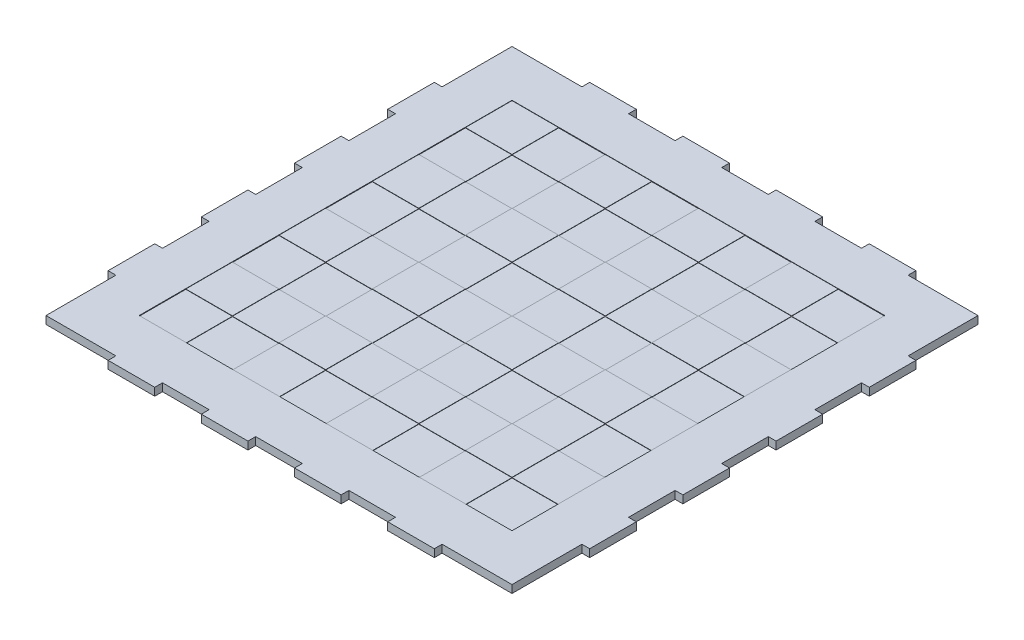
from build123d import *

# Parameters (mm, degrees)
ESQUISSE1_W                     = 381
ESQUISSE1_H                     = 381
BOSS_EXTRU_1_DEPTH              = 6.35
ESQUISSE2_W                     = 38.1
ESQUISSE2_H                     = 6.35
BOSS_EXTRU_2_DEPTH              = 6.35
R_P_TITION_LIN_AIRE1_COUNT      = 4
R_P_TITION_LIN_AIRE1_PITCH      = 76.2
SYM_TRIE1_COPY_1_SKETCH_W       = 38.1
SYM_TRIE1_COPY_1_SKETCH_H       = 6.35
SYM_TRIE1_COPY_1_DEPTH          = 6.35
SYM_TRIE1_COPY_2_SKETCH_W       = 38.1
SYM_TRIE1_COPY_2_SKETCH_H       = 6.35
SYM_TRIE1_COPY_2_DEPTH          = 6.35
SYM_TRIE1_COPY_3_SKETCH_W       = 38.1
SYM_TRIE1_COPY_3_SKETCH_H       = 6.35
SYM_TRIE1_COPY_3_DEPTH          = 6.35
ESQUISSE3_W                     = 38.1
ESQUISSE3_H                     = 6.35
BOSS_EXTRU_3_DEPTH              = 6.35
R_P_TITION_LIN_AIRE2_COUNT      = 4
R_P_TITION_LIN_AIRE2_PITCH      = 76.2
SYM_TRIE2_COPY_1_SKETCH_W       = 38.1
SYM_TRIE2_COPY_1_SKETCH_H       = 6.35
SYM_TRIE2_COPY_1_DEPTH          = 6.35
SYM_TRIE2_COPY_2_SKETCH_W       = 38.1
SYM_TRIE2_COPY_2_SKETCH_H       = 6.35
SYM_TRIE2_COPY_2_DEPTH          = 6.35
SYM_TRIE2_COPY_3_SKETCH_W       = 38.1
SYM_TRIE2_COPY_3_SKETCH_H       = 6.35
SYM_TRIE2_COPY_3_DEPTH          = 6.35
ESQUISSE10_W                    = 304.8
ESQUISSE10_H                    = 304.8
ENL_V_MAT_EXTRU_3_DEPTH         = 0.508
ESQUISSE11_W                    = 38.1
ESQUISSE11_H                    = 38.1
BOSS_EXTRU_5_DEPTH              = 0.254
R_P_TITION_LIN_AIRE3_COUNT      = 4
R_P_TITION_LIN_AIRE3_PITCH      = 76.2
R_P_TITION_LIN_AIRE3_COUNT_DIR2 = 4
R_P_TITION_LIN_AIRE3_PITCH_DIR2 = 76.2
ESQUISSE12_W                    = 38.1
ESQUISSE12_H                    = 38.1
ENL_V_MAT_EXTRU_4_DEPTH         = 0.254
R_P_TITION_LIN_AIRE4_COUNT      = 4
R_P_TITION_LIN_AIRE4_PITCH      = 76.2
R_P_TITION_LIN_AIRE4_COUNT_DIR2 = 4
R_P_TITION_LIN_AIRE4_PITCH_DIR2 = 76.2


with BuildPart() as part:
    # Esquisse1 → Boss.-Extru.1 (new body)
    with BuildSketch(Plane(origin=(0, 0, 0), x_dir=(1, 0, 0), z_dir=(0, 1, 0))):
        Rectangle(ESQUISSE1_W, ESQUISSE1_H)
    extrude(amount=BOSS_EXTRU_1_DEPTH)

    # Esquisse2 → Boss.-Extru.2 (add)
    with BuildSketch(Plane(origin=(190.5, 0, 0), x_dir=(0, 0, -1), z_dir=(1, 0, 0))):
        with Locations((-114.3, 3.175)):
            Rectangle(ESQUISSE2_W, ESQUISSE2_H)
    boss_extru_2 = extrude(amount=BOSS_EXTRU_2_DEPTH)

    # Répétition linéaire1: Boss.-Extru.2 ×4
    with Locations(*[(0, 0, -i * R_P_TITION_LIN_AIRE1_PITCH) for i in range(1, R_P_TITION_LIN_AIRE1_COUNT)]):
        add(boss_extru_2)

    # Symétrie1: Boss.-Extru.2 across plane
    add(boss_extru_2.mirror(Plane(origin=(0, 0, 0), x_dir=(0, 0, 1), z_dir=(1, 0, 0))))

    # Symétrie1 copy 1 sketch → Symétrie1 copy 1 (add)
    with BuildSketch(Plane(origin=(-190.5, 0, -76.2), x_dir=(0, 0, -1), z_dir=(-1, 0, 0))):
        with Locations((-114.3, -3.175)):
            Rectangle(SYM_TRIE1_COPY_1_SKETCH_W, SYM_TRIE1_COPY_1_SKETCH_H)
    extrude(amount=SYM_TRIE1_COPY_1_DEPTH)

    # Symétrie1 copy 2 sketch → Symétrie1 copy 2 (add)
    with BuildSketch(Plane(origin=(-190.5, 0, -152.4), x_dir=(0, 0, -1), z_dir=(-1, 0, 0))):
        with Locations((-114.3, -3.175)):
            Rectangle(SYM_TRIE1_COPY_2_SKETCH_W, SYM_TRIE1_COPY_2_SKETCH_H)
    extrude(amount=SYM_TRIE1_COPY_2_DEPTH)

    # Symétrie1 copy 3 sketch → Symétrie1 copy 3 (add)
    with BuildSketch(Plane(origin=(-190.5, 0, -228.6), x_dir=(0, 0, -1), z_dir=(-1, 0, 0))):
        with Locations((-114.3, -3.175)):
            Rectangle(SYM_TRIE1_COPY_3_SKETCH_W, SYM_TRIE1_COPY_3_SKETCH_H)
    extrude(amount=SYM_TRIE1_COPY_3_DEPTH)

    # Esquisse3 → Boss.-Extru.3 (add)
    with BuildSketch(Plane.XY.offset(190.5)):
        with Locations((114.3, 3.175)):
            Rectangle(ESQUISSE3_W, ESQUISSE3_H)
    boss_extru_3 = extrude(amount=BOSS_EXTRU_3_DEPTH)

    # Répétition linéaire2: Boss.-Extru.3 ×4
    with Locations(*[(-i * R_P_TITION_LIN_AIRE2_PITCH, 0, 0) for i in range(1, R_P_TITION_LIN_AIRE2_COUNT)]):
        add(boss_extru_3)

    # Symétrie2: Boss.-Extru.3 across plane
    add(boss_extru_3.mirror(Plane.XY))

    # Symétrie2 copy 1 sketch → Symétrie2 copy 1 (add)
    with BuildSketch(Plane(origin=(-76.2, 0, -190.5), x_dir=(1, 0, 0), z_dir=(0, 0, -1))):
        with Locations((114.3, -3.175)):
            Rectangle(SYM_TRIE2_COPY_1_SKETCH_W, SYM_TRIE2_COPY_1_SKETCH_H)
    extrude(amount=SYM_TRIE2_COPY_1_DEPTH)

    # Symétrie2 copy 2 sketch → Symétrie2 copy 2 (add)
    with BuildSketch(Plane(origin=(-152.4, 0, -190.5), x_dir=(1, 0, 0), z_dir=(0, 0, -1))):
        with Locations((114.3, -3.175)):
            Rectangle(SYM_TRIE2_COPY_2_SKETCH_W, SYM_TRIE2_COPY_2_SKETCH_H)
    extrude(amount=SYM_TRIE2_COPY_2_DEPTH)

    # Symétrie2 copy 3 sketch → Symétrie2 copy 3 (add)
    with BuildSketch(Plane(origin=(-228.6, 0, -190.5), x_dir=(1, 0, 0), z_dir=(0, 0, -1))):
        with Locations((114.3, -3.175)):
            Rectangle(SYM_TRIE2_COPY_3_SKETCH_W, SYM_TRIE2_COPY_3_SKETCH_H)
    extrude(amount=SYM_TRIE2_COPY_3_DEPTH)

    # Esquisse10 → Enlèv. mat.-Extru.3 (cut)
    with BuildSketch(Plane(origin=(0, 6.35, 0), x_dir=(1, 0, 0), z_dir=(0, 1, 0))):
        Rectangle(ESQUISSE10_W, ESQUISSE10_H)
    extrude(amount=-ENL_V_MAT_EXTRU_3_DEPTH, mode=Mode.SUBTRACT)

    # Esquisse11 → Boss.-Extru.5 (add)
    with BuildSketch(Plane(origin=(0, 5.842, 0), x_dir=(1, 0, 0), z_dir=(0, 1, 0))):
        with Locations((-133.35, 133.35)):
            Rectangle(ESQUISSE11_W, ESQUISSE11_H)
    boss_extru_5 = extrude(amount=BOSS_EXTRU_5_DEPTH)

    # Répétition linéaire3: Boss.-Extru.5 4 × 4
    with Locations(*[(j * R_P_TITION_LIN_AIRE3_PITCH_DIR2, 0, i * R_P_TITION_LIN_AIRE3_PITCH) for i in range(R_P_TITION_LIN_AIRE3_COUNT) for j in range(R_P_TITION_LIN_AIRE3_COUNT_DIR2) if (i, j) != (0, 0)]):
        add(boss_extru_5)

    # Esquisse12 → Enlèv. mat.-Extru.4 (cut)
    with BuildSketch(Plane(origin=(0, 5.842, 0), x_dir=(1, 0, 0), z_dir=(0, 1, 0))):
        with Locations((-95.25, 95.25)):
            Rectangle(ESQUISSE12_W, ESQUISSE12_H)
    enl_v_mat_extru_4 = extrude(amount=-ENL_V_MAT_EXTRU_4_DEPTH, mode=Mode.SUBTRACT)

    # Répétition linéaire4: Enl_v. mat.-Extru.4 4 × 4
    with Locations(*[(j * R_P_TITION_LIN_AIRE4_PITCH_DIR2, 0, i * R_P_TITION_LIN_AIRE4_PITCH) for i in range(R_P_TITION_LIN_AIRE4_COUNT) for j in range(R_P_TITION_LIN_AIRE4_COUNT_DIR2) if (i, j) != (0, 0)]):
        add(enl_v_mat_extru_4, mode=Mode.SUBTRACT)


solid = part.part
